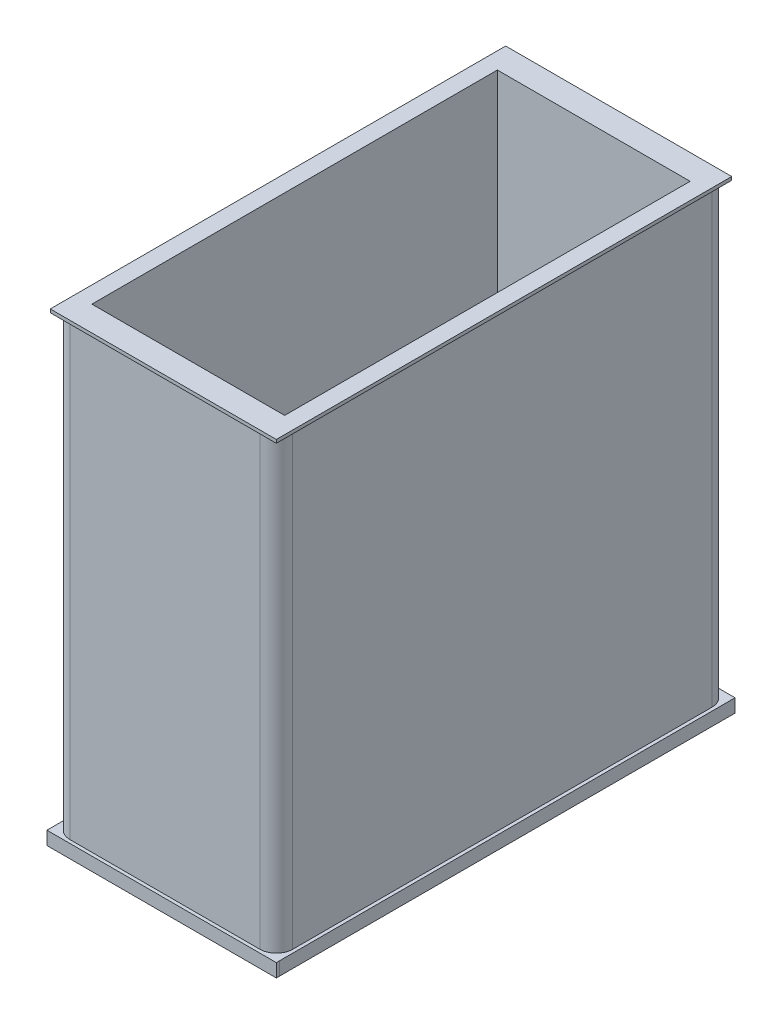
from build123d import *

# Parameters (mm, degrees)
SKETCH1_W            = 169.926
SKETCH1_H            = 344.932
BOSS_EXTRUDE1_DEPTH  = 379.984
SKETCH7_W            = 344.932
SKETCH7_H            = 10.16
BOSS_EXTRUDE4_DEPTH  = 2.54
SKETCH8_W            = 344.932
SKETCH8_H            = 10.16
BOSS_EXTRUDE5_DEPTH  = 2.54
SKETCH9_W            = 175.006
SKETCH9_H            = 10.16
BOSS_EXTRUDE6_DEPTH  = 2.54
SKETCH13_W           = 344.932
SKETCH13_H           = 2.54
BOSS_EXTRUDE9_DEPTH  = 1.27
SKETCH14_W           = 171.196
SKETCH14_H           = 2.54
BOSS_EXTRUDE10_DEPTH = 1.27
SKETCH15_W           = 346.202
SKETCH15_H           = 2.54
BOSS_EXTRUDE11_DEPTH = 1.27
SKETCH16_W           = 172.466
SKETCH16_H           = 2.54
BOSS_EXTRUDE12_DEPTH = 1.27
FILLET1_R            = 12.54
SKETCH23_W           = 175.014872456
SKETCH23_H           = 10.16
BOSS_EXTRUDE15_DEPTH = 2.54
SKETCH25_W           = 180.28813578
SKETCH25_H           = 28.656047844
CUT_EXTRUDE1_DEPTH   = 474.472
SKETCH26_W           = 147.066
SKETCH26_H           = 309.372
CUT_EXTRUDE2_DEPTH   = 345.948


with BuildPart() as part:
    # Sketch1 → Boss-Extrude1 (new body)
    with BuildSketch(Plane(origin=(0, 0, 0), x_dir=(1, 0, 0), z_dir=(0, 1, 0))):
        with Locations((18.629158276, -37.477981942)):
            Rectangle(SKETCH1_W, SKETCH1_H)
    extrude(amount=BOSS_EXTRUDE1_DEPTH)

    # Sketch7 → Boss-Extrude4 (add)
    with BuildSketch(Plane.ZY.offset(66.333841724)):
        with Locations((37.477981942, 5.08)):
            Rectangle(SKETCH7_W, SKETCH7_H)
    extrude(amount=BOSS_EXTRUDE4_DEPTH)

    # Sketch8 → Boss-Extrude5 (add)
    with BuildSketch(Plane(origin=(103.592158276, 0, 0), x_dir=(0, 0, -1), z_dir=(1, 0, 0))):
        with Locations((-37.477981942, 5.08)):
            Rectangle(SKETCH8_W, SKETCH8_H)
    extrude(amount=BOSS_EXTRUDE5_DEPTH)

    # Sketch9 → Boss-Extrude6 (add)
    with BuildSketch(Plane(origin=(0, 0, -134.988018058), x_dir=(-1, 0, 0), z_dir=(0, 0, -1))):
        with Locations((-18.629158276, 5.08)):
            Rectangle(SKETCH9_W, SKETCH9_H)
    extrude(amount=BOSS_EXTRUDE6_DEPTH)

    # Sketch13 → Boss-Extrude9 (add)
    with BuildSketch(Plane(origin=(103.592158276, 0, 0), x_dir=(0, 0, -1), z_dir=(1, 0, 0))):
        with Locations((-37.477981942, 353.314)):
            Rectangle(SKETCH13_W, SKETCH13_H)
    extrude(amount=BOSS_EXTRUDE9_DEPTH)

    # Sketch14 → Boss-Extrude10 (add)
    with BuildSketch(Plane(origin=(0, 0, -134.988018058), x_dir=(-1, 0, 0), z_dir=(0, 0, -1))):
        with Locations((-19.264158276, 353.314)):
            Rectangle(SKETCH14_W, SKETCH14_H)
    extrude(amount=BOSS_EXTRUDE10_DEPTH)

    # Sketch15 → Boss-Extrude11 (add)
    with BuildSketch(Plane.ZY.offset(66.333841724)):
        with Locations((36.842981942, 353.314)):
            Rectangle(SKETCH15_W, SKETCH15_H)
    extrude(amount=BOSS_EXTRUDE11_DEPTH)

    # Sketch16 → Boss-Extrude12 (add)
    with BuildSketch(Plane.XY.offset(209.943981942)):
        with Locations((18.629158276, 353.314)):
            Rectangle(SKETCH16_W, SKETCH16_H)
    extrude(amount=BOSS_EXTRUDE12_DEPTH)

    # Fillet1
    fillet1_edges = [part.edges().sort_by_distance(p)[0] for p in [
        (103.592158276, 379.984, 37.477981942),
        (18.629158276, 379.984, -134.988018058),
        (-66.333841724, 379.984, 37.477981942),
        (103.592158276, 181.102, 209.943981942),
        (103.592158276, 181.102, -134.988018058),
        (-66.333841724, 181.102, -134.988018058),
        (-66.333841724, 367.284, -134.988018058),
        (103.592158276, 367.284, -134.988018058),
        (103.592158276, 367.284, 209.943981942),
        (-66.333841724, 367.284, 209.943981942),
        (-66.333841724, 181.102, 209.943981942),
        (18.629158276, 379.984, 209.943981942),
    ]]
    fillet(fillet1_edges, radius=FILLET1_R)

    # Sketch23 → Boss-Extrude15 (add)
    with BuildSketch(Plane.XY.offset(209.943981942)):
        with Locations((18.633594504, 5.08)):
            Rectangle(SKETCH23_W, SKETCH23_H)
    extrude(amount=BOSS_EXTRUDE15_DEPTH)

    # Sketch25 → Cut-Extrude1 (cut)
    with BuildSketch(Plane(origin=(0, 0, -134.988018058), x_dir=(-1, 0, 0), z_dir=(0, 0, -1))):
        with Locations((-13.448090386, 368.912023922)):
            Rectangle(SKETCH25_W, SKETCH25_H)
    extrude(amount=-CUT_EXTRUDE1_DEPTH, mode=Mode.SUBTRACT)

    # Sketch26 → Cut-Extrude2 (cut)
    with BuildSketch(Plane(origin=(0, 354.584, 0), x_dir=(1, 0, 0), z_dir=(0, 1, 0))):
        with Locations((18.629158276, -37.477981942)):
            Rectangle(SKETCH26_W, SKETCH26_H)
    extrude(amount=-CUT_EXTRUDE2_DEPTH, mode=Mode.SUBTRACT)


solid = part.part
